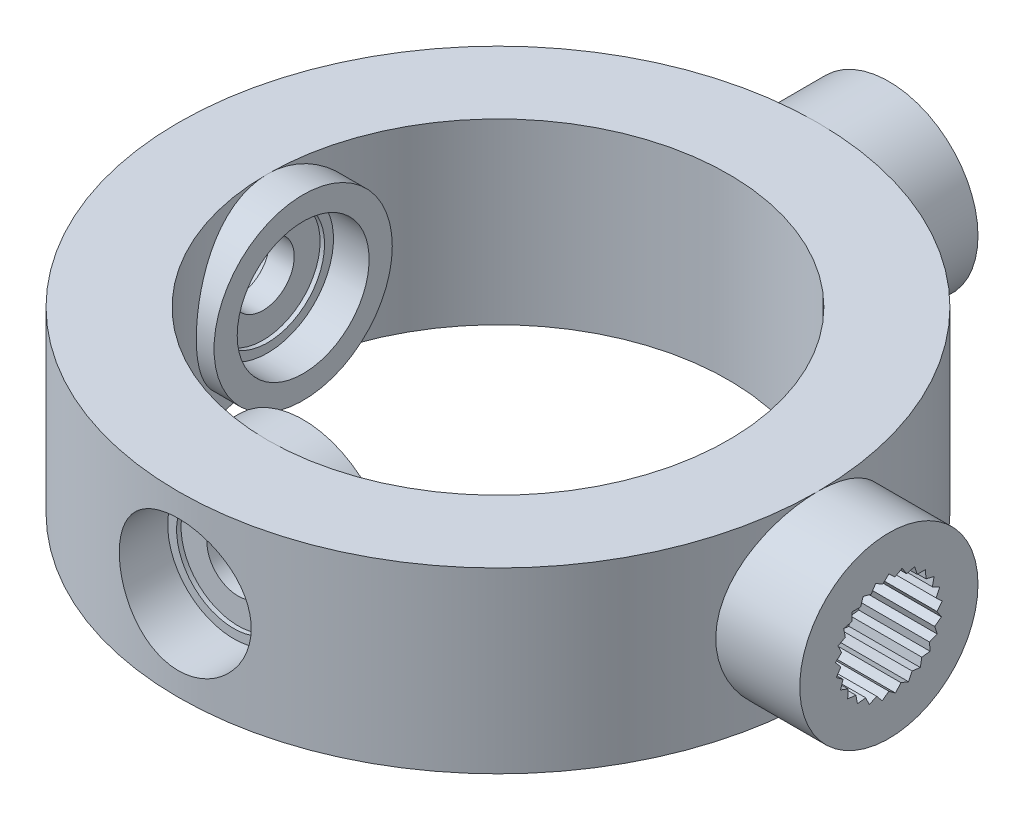
from build123d import *

# Parameters (mm, degrees)
SKETCH1_R           = 17.92893219
BOSS_EXTRUDE1_DEPTH = 10
SKETCH2_R           = 12.92893219
CUT_EXTRUDE1_DEPTH  = 11
BOSS_EXTRUDE2_REACH = 41.858
SKETCH4_R           = 5
BOSS_EXTRUDE4_REACH = 9
SKETCH7_R           = 5
SKETCH8_R           = 1.75
CUT_EXTRUDE3_DEPTH  = 7
BOSS_EXTRUDE5_REACH = 41.858
SKETCH11_R          = 5
BOSS_EXTRUDE6_REACH = 9
SKETCH12_R          = 5
SKETCH13_R          = 1.75
CUT_EXTRUDE4_DEPTH  = 7
CUT_EXTRUDE5_DEPTH  = 4
CIRPATTERN1_COUNT   = 2
CIRPATTERN1_ANGLE   = 270
SKETCH15_R          = 3.7
CUT_EXTRUDE6_DEPTH  = 3.1
SKETCH16_R          = 3.7
CUT_EXTRUDE7_DEPTH  = 2
SKETCH17_R          = 3.2
SKETCH17_R_2        = 1.75
CUT_EXTRUDE8_DEPTH  = 0.25
SKETCH18_R          = 3.2
SKETCH18_R_2        = 1.75
CUT_EXTRUDE9_DEPTH  = 0.25
CIRPATTERN2_COUNT   = 2
CIRPATTERN2_ANGLE   = 90


with BuildPart() as part:
    # Sketch1 → Boss-Extrude1 (new body)
    with BuildSketch(Plane(origin=(0, 0, 0), x_dir=(1, 0, 0), z_dir=(0, 1, 0))):
        Circle(SKETCH1_R)
    extrude(amount=BOSS_EXTRUDE1_DEPTH)

    # Sketch2 → Cut-Extrude1 (cut, through all)
    with BuildSketch(Plane(origin=(0, 10, 0), x_dir=(1, 0, 0), z_dir=(0, 1, 0))):
        Circle(SKETCH2_R)
    extrude(amount=-CUT_EXTRUDE1_DEPTH, mode=Mode.SUBTRACT)

    # Sketch4 → Boss-Extrude2 (add, up to next)
    with BuildSketch(Plane(origin=(21.92893219, 0, 0), x_dir=(0, 0, -1), z_dir=(1, 0, 0)), mode=Mode.PRIVATE) as boss_extrude2_sk1:
        with Locations((0, 5)):
            Circle(SKETCH4_R)
    boss_extrude2_tool1 = extrude(boss_extrude2_sk1.sketch, amount=-BOSS_EXTRUDE2_REACH, mode=Mode.PRIVATE) - part.part
    add(boss_extrude2_tool1.solids().sort_by_distance((21.928932, 5, 0))[0])

    # Sketch7 → Boss-Extrude4 (add, up to next)
    with BuildSketch(Plane(origin=(-10.92893219, 0, 0), x_dir=(0, 0, -1), z_dir=(1, 0, 0)), mode=Mode.PRIVATE) as boss_extrude4_sk1:
        with Locations((0, 5)):
            Circle(SKETCH7_R)
    boss_extrude4_tool1 = extrude(boss_extrude4_sk1.sketch, amount=-BOSS_EXTRUDE4_REACH, mode=Mode.PRIVATE) - part.part
    add(boss_extrude4_tool1.solids().sort_by_distance((-10.928932, 5, 0))[0])

    # Sketch8 → Cut-Extrude3 (cut)
    with BuildSketch(Plane(origin=(-17.92893219, 0, 0), x_dir=(0, 0, -1), z_dir=(1, 0, 0))):
        with Locations((0, 5)):
            Circle(SKETCH8_R)
    extrude(amount=CUT_EXTRUDE3_DEPTH, mode=Mode.SUBTRACT)

    # Sketch11 → Boss-Extrude5 (add, up to next)
    with BuildSketch(Plane.XY.offset(-21.92893219), mode=Mode.PRIVATE) as boss_extrude5_sk1:
        with Locations((0, 5)):
            Circle(SKETCH11_R)
    boss_extrude5_tool1 = extrude(boss_extrude5_sk1.sketch, amount=BOSS_EXTRUDE5_REACH, mode=Mode.PRIVATE) - part.part
    add(boss_extrude5_tool1.solids().sort_by_distance((0, 5, -21.928932))[0])

    # Sketch12 → Boss-Extrude6 (add, up to next)
    with BuildSketch(Plane.XY.offset(10.92893219), mode=Mode.PRIVATE) as boss_extrude6_sk1:
        with Locations((0, 5)):
            Circle(SKETCH12_R)
    boss_extrude6_tool1 = extrude(boss_extrude6_sk1.sketch, amount=BOSS_EXTRUDE6_REACH, mode=Mode.PRIVATE) - part.part
    add(boss_extrude6_tool1.solids().sort_by_distance((0, 5, 10.928932))[0])

    # Sketch13 → Cut-Extrude4 (cut)
    with BuildSketch(Plane.XY.offset(17.92893219)):
        with Locations((0, 5)):
            Circle(SKETCH13_R)
    extrude(amount=-CUT_EXTRUDE4_DEPTH, mode=Mode.SUBTRACT)

    # Sketch14 → Cut-Extrude5 (cut)
    with BuildSketch(Plane(origin=(0, 0, -21.92893219), x_dir=(-1, 0, 0), z_dir=(0, 0, -1))):
        Polygon((0, 8), (-0.338379883, 7.678552586), (-0.746069661, 7.905749483), (-0.993877997, 7.510249276), (-1.445261022, 7.62892004), (-1.586927102, 7.184217772), (-2.053641318, 7.186905882), (-2.08026374, 6.720943832), (-2.532983777, 6.607480385), (-2.442889756, 6.149536662), (-2.853169549, 5.927050983), (-2.652020025, 5.505899876), (-2.994080185, 5.188371559), (-2.694514123, 4.830475541), (-2.946861752, 4.437856056), (-2.567701988, 4.16570305), (-2.714481157, 3.722662125), (-2.279551694, 3.553352505), (-2.311539728, 3.087728031), (-1.848168783, 3.031900143), (-1.763355757, 2.572949017), (-1.300658631, 2.634110733), (-1.104373658, 2.210670542), (-0.671423314, 2.384978846), (-0.375999701, 2.023655896), (0, 2.300158357), (0.375999701, 2.023655896), (0.671423314, 2.384978846), (1.104373658, 2.210670542), (1.300658631, 2.634110733), (1.763355757, 2.572949017), (1.848168783, 3.031900143), (2.311539728, 3.087728031), (2.279551694, 3.553352505), (2.714481157, 3.722662125), (2.567701988, 4.16570305), (2.946861752, 4.437856056), (2.694514123, 4.830475541), (2.994080185, 5.188371559), (2.652020025, 5.505899876), (2.853169549, 5.927050983), (2.442889756, 6.149536662), (2.532983777, 6.607480385), (2.08026374, 6.720943832), (2.053641318, 7.186905882), (1.586927102, 7.184217772), (1.445261022, 7.62892004), (0.993877997, 7.510249276), (0.746069661, 7.905749483), (0.338379883, 7.678552586), align=None)
    cut_extrude5 = extrude(amount=-CUT_EXTRUDE5_DEPTH, mode=Mode.SUBTRACT)

    # CirPattern1: Cut-Extrude5 ×2 about axis
    cirpattern1_axis = Axis((0, 0, 0), (0, 1, 0))
    for i in range(1, CIRPATTERN1_COUNT):
        add(cut_extrude5.rotate(cirpattern1_axis, i * CIRPATTERN1_ANGLE / (CIRPATTERN1_COUNT - 1)), mode=Mode.SUBTRACT)

    # Sketch15 → Cut-Extrude6 (cut)
    with BuildSketch(Plane.XY.offset(17.92893219)):
        with Locations((0, 5)):
            Circle(SKETCH15_R)
    cut_extrude6 = extrude(amount=-CUT_EXTRUDE6_DEPTH, mode=Mode.SUBTRACT)

    # Sketch16 → Cut-Extrude7 (cut)
    with BuildSketch(Plane.XY.offset(10.92893219)):
        with Locations((0, 5)):
            Circle(SKETCH16_R)
    cut_extrude7 = extrude(amount=CUT_EXTRUDE7_DEPTH, mode=Mode.SUBTRACT)

    # Sketch17 → Cut-Extrude8 (cut)
    with BuildSketch(Plane.XY.offset(14.82893219)):
        with Locations((0, 5)):
            Circle(SKETCH17_R)
        with Locations((0, 5)):
            Circle(SKETCH17_R_2, mode=Mode.SUBTRACT)
    cut_extrude8 = extrude(amount=-CUT_EXTRUDE8_DEPTH, mode=Mode.SUBTRACT)

    # Sketch18 → Cut-Extrude9 (cut)
    with BuildSketch(Plane(origin=(0, 0, 12.92893219), x_dir=(-1, 0, 0), z_dir=(0, 0, -1))):
        with Locations((0, 5)):
            Circle(SKETCH18_R)
        with Locations((0, 5)):
            Circle(SKETCH18_R_2, mode=Mode.SUBTRACT)
    cut_extrude9 = extrude(amount=-CUT_EXTRUDE9_DEPTH, mode=Mode.SUBTRACT)

    # CirPattern2: Cut-Extrude6, Cut-Extrude7, Cut-Extrude8, Cut-Extrude9 ×2 about axis
    cirpattern2_axis = Axis((0, 10, 0), (0, -1, 0))
    for i in range(1, CIRPATTERN2_COUNT):
        add(cut_extrude6.rotate(cirpattern2_axis, i * CIRPATTERN2_ANGLE / (CIRPATTERN2_COUNT - 1)), mode=Mode.SUBTRACT)
        add(cut_extrude7.rotate(cirpattern2_axis, i * CIRPATTERN2_ANGLE / (CIRPATTERN2_COUNT - 1)), mode=Mode.SUBTRACT)
        add(cut_extrude8.rotate(cirpattern2_axis, i * CIRPATTERN2_ANGLE / (CIRPATTERN2_COUNT - 1)), mode=Mode.SUBTRACT)
        add(cut_extrude9.rotate(cirpattern2_axis, i * CIRPATTERN2_ANGLE / (CIRPATTERN2_COUNT - 1)), mode=Mode.SUBTRACT)


solid = part.part
